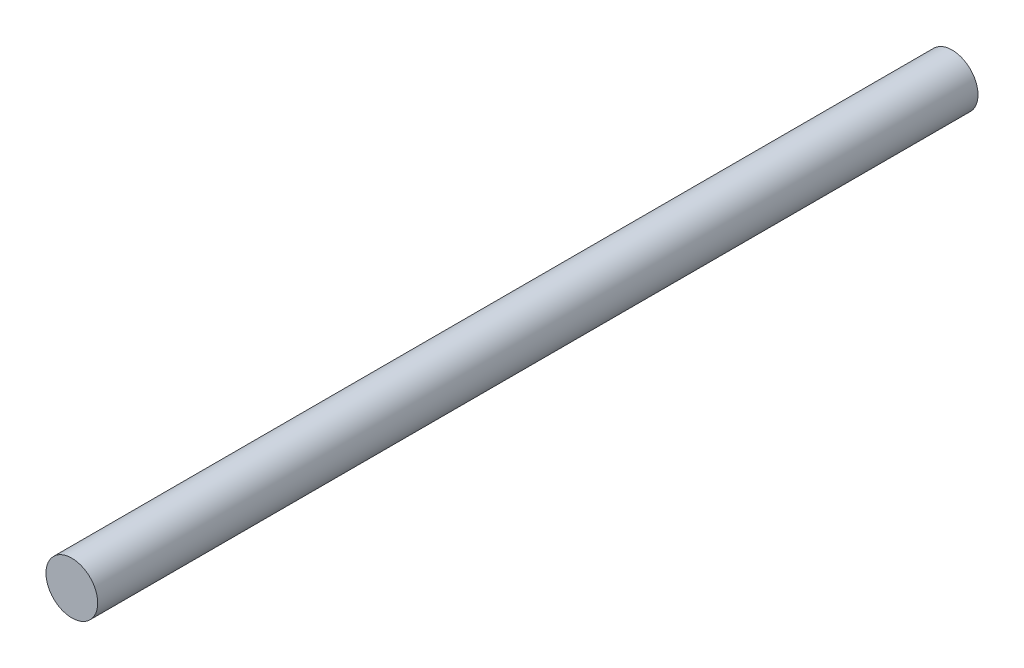
from build123d import *

# Parameters (mm, degrees)
SKETCH1_R           = 4
BOSS_EXTRUDE1_DEPTH = 136


with BuildPart() as part:
    # Sketch1 → Boss-Extrude1 (new body)
    with BuildSketch(Plane.XY):
        Circle(SKETCH1_R)
    extrude(amount=BOSS_EXTRUDE1_DEPTH)


solid = part.part
